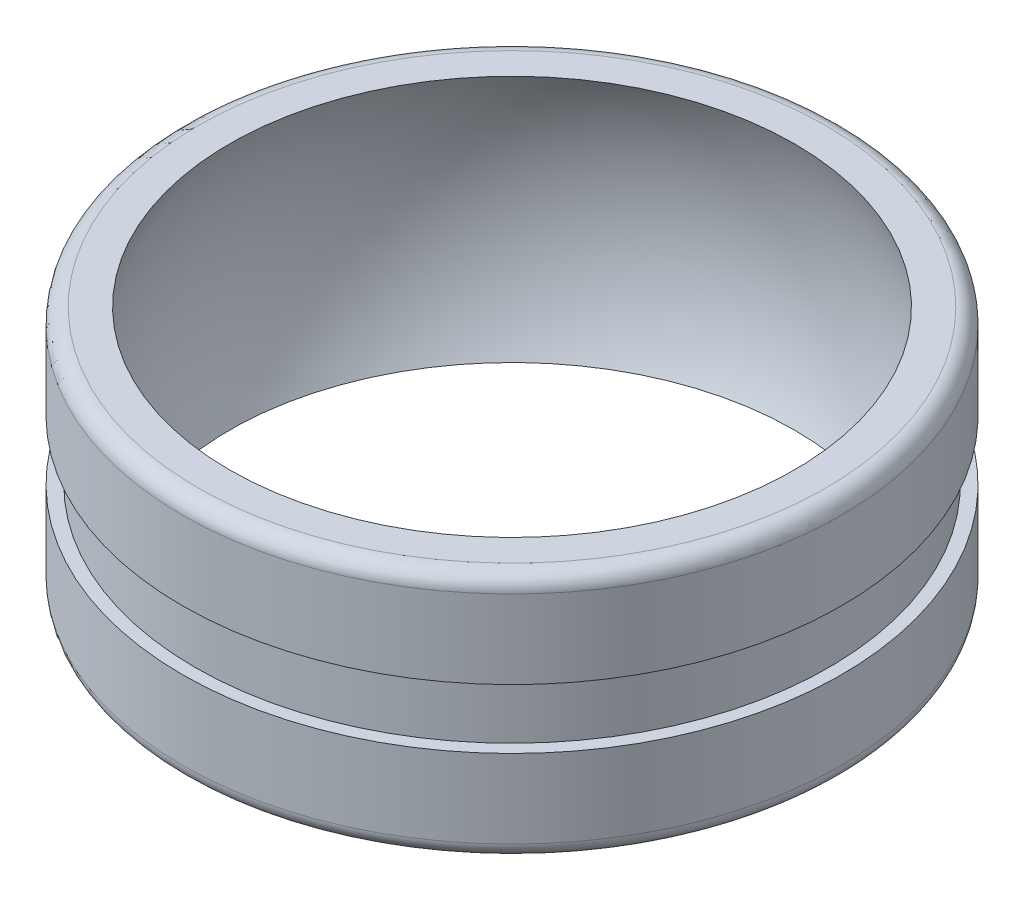
from build123d import *

# Parameters (mm, degrees)
FILLET1_R = 1


with BuildPart() as part:
    # Sketch1 → Revolve1 (revolve)
    with BuildSketch(Plane(origin=(0, 0, 0), x_dir=(0, 0, -1), z_dir=(1, 0, 0)), mode=Mode.PRIVATE) as revolve1_sk:
        with BuildLine():
            Line((21, 7.9), (21, 1.9))
            Line((21, 1.9), (20.2, 1.9))
            Line((20.2, 1.9), (20.2, -1.9))
            Line((20.2, -1.9), (21, -1.9))
            Line((21, -1.9), (21, -7.9))
            Line((21, -7.9), (18, -7.9))
            ThreePointArc((18, -7.9), (19.826255845, 0), (18, 7.9))
            Line((18, 7.9), (21, 7.9))
        make_face()
    revolve(revolve1_sk.sketch.rotate(Axis((0, 7.9, 0), (0, -1, 0)), 180), axis=Axis((0, 7.9, 0), (0, -1, 0)))  # turned: the seam where the file's is

    # Fillet1
    fillet1_edges = [part.edges().sort_by_distance(p)[0] for p in [
        (0, -7.9, -21),
        (0, 7.9, -21),
    ]]
    fillet(fillet1_edges, radius=FILLET1_R)


solid = part.part
